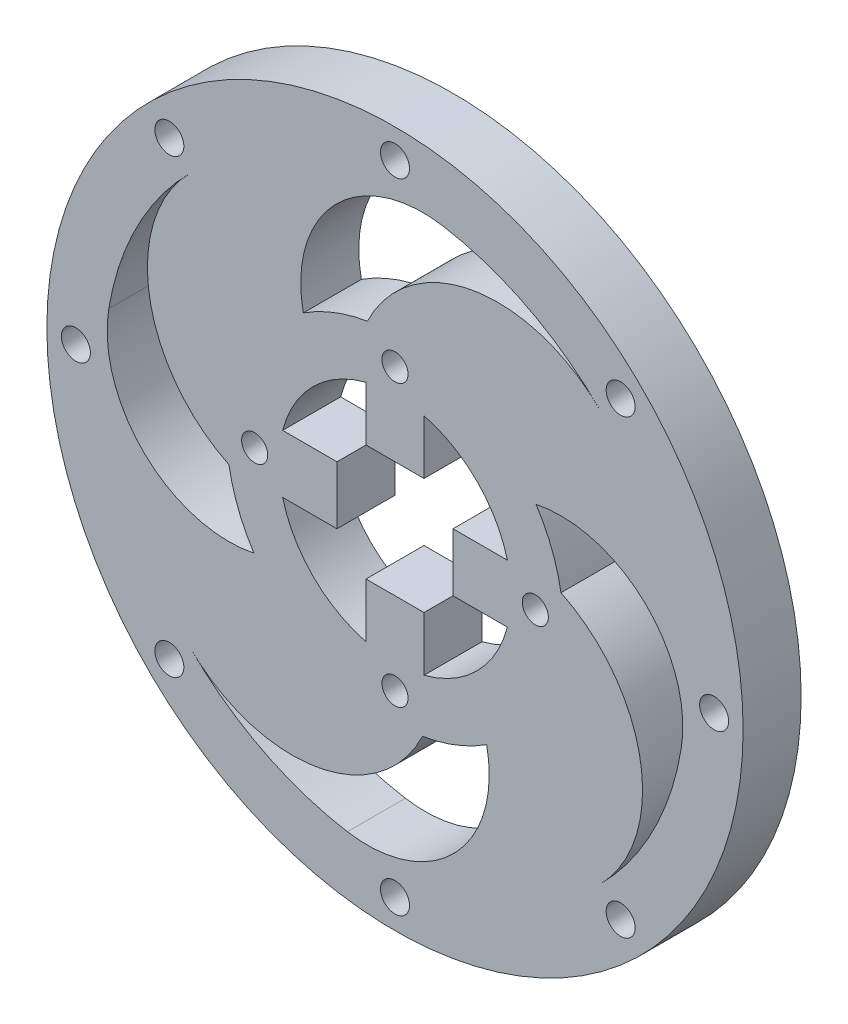
from build123d import *

# Parameters (mm, degrees)
SKETCH6_R                        = 29
SKETCH6_R_2                      = 20
INNER_RING_DEPTH                 = 10
MOTOR_CONNECTOR_CUT_DEPTH        = 10
SKETCH8_R                        = 2.25
MOTOR_CONNECTOR_HOLES_DEPTH      = 1
MOTOR_CONNECTOR_HOLES_DEPTH_BACK = 18
MIDDLE_PATTERN_DEPTH             = 10
SKETCH9_R                        = 60
SKETCH9_R_2                      = 50
SKETCH9_R_3                      = 2.5
BOSS_EXTRUDE1_DEPTH              = 10


with BuildPart() as part:
    # Sketch6 → Inner Ring (new body)
    with BuildSketch(Plane.XY):
        Circle(SKETCH6_R)
        Circle(SKETCH6_R_2, mode=Mode.SUBTRACT)
    extrude(amount=-INNER_RING_DEPTH)

    # Sketch7 → Motor Connector Cut (add)
    with BuildSketch(Plane.XY):
        with BuildLine():
            ThreePointArc((20, 0), (19.840593925, 2.52008585), (19.364916731, 5))
            Line((19.364916731, 5), (9.999996731, 5))
            Line((9.999996731, 5), (9.999996731, -5))
            Line((9.999996731, -5), (19.364916731, -5))
            ThreePointArc((19.364916731, -5), (19.840593925, -2.52008585), (20, 0))
        make_face()
        with BuildLine():
            ThreePointArc((5, 19.364916731), (0, 20), (-5, 19.364916731))
            Line((-5, 19.364916731), (-5, 9.999996731))
            Line((-5, 9.999996731), (5, 9.999996731))
            Line((5, 9.999996731), (5, 19.364916731))
        make_face()
        with BuildLine():
            Line((-9.999996731, -5), (-9.999996731, 5))
            Line((-9.999996731, 5), (-19.364916731, 5))
            ThreePointArc((-19.364916731, 5), (-20, 0), (-19.364916731, -5))
            Line((-19.364916731, -5), (-9.999996731, -5))
        make_face()
        with BuildLine():
            Line((-5, -9.999996731), (-5, -19.364916731))
            ThreePointArc((-5, -19.364916731), (0, -20), (5, -19.364916731))
            Line((5, -19.364916731), (5, -9.999996731))
            Line((5, -9.999996731), (-5, -9.999996731))
        make_face()
    extrude(amount=-MOTOR_CONNECTOR_CUT_DEPTH)

    # Sketch8 → Motor Connector Holes (cut, two sides)
    with BuildSketch(Plane.XY) as motor_connector_holes_sk:
        with Locations((0, 24.182458366)):
            Circle(SKETCH8_R)
        with Locations((24.182458366, 0)):
            Circle(SKETCH8_R)
        with Locations((0, -24.182458366)):
            Circle(SKETCH8_R)
        with Locations((-24.182458366, 0)):
            Circle(SKETCH8_R)
    extrude(amount=MOTOR_CONNECTOR_HOLES_DEPTH, mode=Mode.SUBTRACT)
    extrude(motor_connector_holes_sk.sketch, amount=-MOTOR_CONNECTOR_HOLES_DEPTH_BACK, mode=Mode.SUBTRACT)

    # Sketch10 → Middle Pattern (add)
    with BuildSketch(Plane.XY):
        with BuildLine():
            ThreePointArc((28.607215414, 4.756808408), (26.539406056, -11.690163651), (15.800414568, -24.317625284))
            ThreePointArc((15.800414568, -24.317625284), (10.393277118, -43.149392299), (-8.201394307, -49.322785114))
            ThreePointArc((-8.201394307, -49.322785114), (15.267827816, -47.611904328), (35.355339059, -35.355339059))
            ThreePointArc((35.355339059, -35.355339059), (42.321804958, -13.559663633), (28.607215414, 4.756808408))
        make_face()
        with BuildLine():
            ThreePointArc((24.317625284, 15.800414568), (43.149392359, 10.39327706), (49.322785087, -8.201394473))
            ThreePointArc((49.322785087, -8.201394473), (47.611904354, 15.267827736), (35.355339059, 35.355339059))
            ThreePointArc((35.355339059, 35.355339059), (13.559663633, 42.321804958), (-4.756808408, 28.607215414))
            ThreePointArc((-4.756808408, 28.607215414), (11.690163651, 26.539406056), (24.317625284, 15.800414568))
        make_face()
        with BuildLine():
            ThreePointArc((8.201394106, 49.322785148), (-15.267827902, 47.611904301), (-35.355339044, 35.355339075))
            ThreePointArc((-35.355339044, 35.355339075), (-42.32180496, 13.559663644), (-28.607215414, -4.756808408))
            ThreePointArc((-28.607215414, -4.756808408), (-26.539406056, 11.690163651), (-15.800414568, 24.317625284))
            ThreePointArc((-15.800414568, 24.317625284), (-10.393277189, 43.149392225), (8.201394106, 49.322785148))
        make_face()
        with BuildLine():
            ThreePointArc((4.756808408, -28.607215414), (-11.690163651, -26.539406056), (-24.317625284, -15.800414568))
            ThreePointArc((-24.317625284, -15.800414568), (-43.149392012, -10.393277393), (-49.322785244, 8.201393524))
            ThreePointArc((-49.322785244, 8.201393524), (-47.61190416, -15.267828343), (-35.355338839, -35.35533928))
            ThreePointArc((-35.355338839, -35.35533928), (-13.559663479, -42.321804932), (4.756808408, -28.607215414))
        make_face()
    extrude(amount=-MIDDLE_PATTERN_DEPTH)

    # Sketch9 → Boss-Extrude1 (add)
    with BuildSketch(Plane.XY):
        Circle(SKETCH9_R)
        Circle(SKETCH9_R_2, mode=Mode.SUBTRACT)
        with Locations((0, 55)):
            Circle(SKETCH9_R_3, mode=Mode.SUBTRACT)
        with Locations((-38.890872965, 38.890872965)):
            Circle(SKETCH9_R_3, mode=Mode.SUBTRACT)
        with Locations((-55, 0)):
            Circle(SKETCH9_R_3, mode=Mode.SUBTRACT)
        with Locations((-38.890872965, -38.890872965)):
            Circle(SKETCH9_R_3, mode=Mode.SUBTRACT)
        with Locations((0, -55)):
            Circle(SKETCH9_R_3, mode=Mode.SUBTRACT)
        with Locations((38.890872965, -38.890872965)):
            Circle(SKETCH9_R_3, mode=Mode.SUBTRACT)
        with Locations((55, 0)):
            Circle(SKETCH9_R_3, mode=Mode.SUBTRACT)
        with Locations((38.890872965, 38.890872965)):
            Circle(SKETCH9_R_3, mode=Mode.SUBTRACT)
    extrude(amount=-BOSS_EXTRUDE1_DEPTH)


solid = part.part
